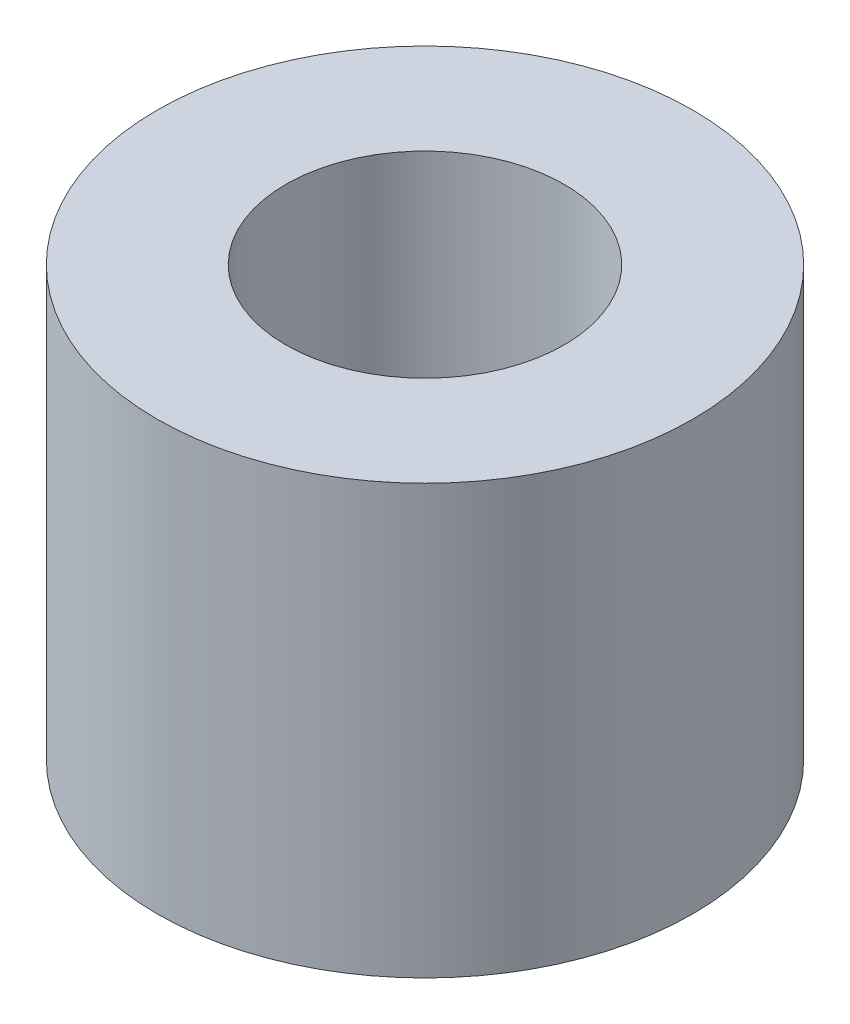
from build123d import *

# Parameters (mm, degrees)
SKETCH1_R                 = 3.175
BOSS_EXTRUDE1_DEPTH       = 2.54
M4X0_7_TAPPED_HOLE1_D     = 3.3
M4X0_7_TAPPED_HOLE1_DEPTH = 9.906


with BuildPart() as part:
    # Sketch1 → Boss-Extrude1 (new body, symmetric)
    with BuildSketch(Plane(origin=(0, 0, 0), x_dir=(1, 0, 0), z_dir=(0, 1, 0))):
        Circle(SKETCH1_R)
    extrude(amount=BOSS_EXTRUDE1_DEPTH, both=True)

    # M4x0.7 Tapped Hole1
    with Locations(Plane(origin=(0, 2.54, 0), x_dir=(1, 0, 0), z_dir=(0, 1, 0))):
        with Locations((0, 0)):
            Hole(M4X0_7_TAPPED_HOLE1_D / 2, depth=M4X0_7_TAPPED_HOLE1_DEPTH)


solid = part.part
